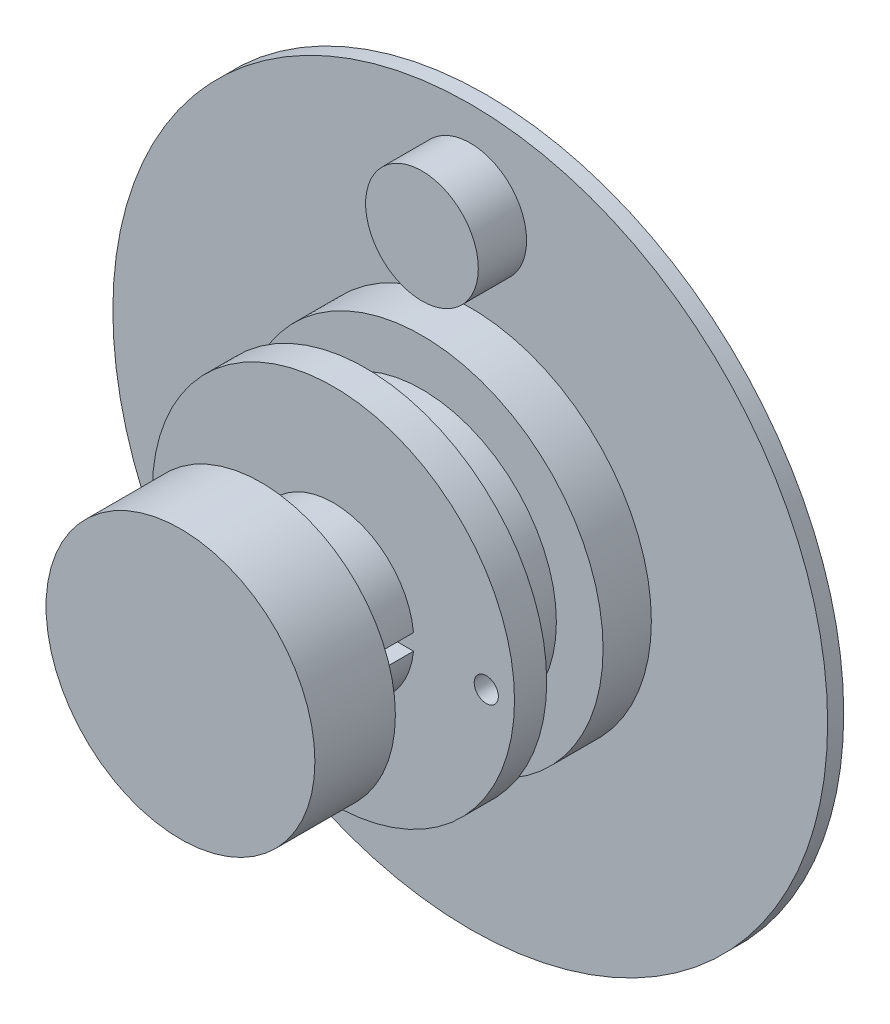
from build123d import *

# Parameters (mm, degrees)
SKETCH1_R           = 22.2
BOSS_EXTRUDE1_DEPTH = 1
BOSS_EXTRUDE2_START = 1
SKETCH2_R           = 11.25
BOSS_EXTRUDE2_DEPTH = 8.5
BOSS_EXTRUDE3_START = 9.5
SKETCH3_R           = 5
BOSS_EXTRUDE3_DEPTH = 9.5
CUT_EXTRUDE1_START  = 19
SKETCH4_W           = 11.621745696
SKETCH4_H           = 1
CUT_EXTRUDE1_DEPTH  = 9.5
BOSS_EXTRUDE4_START = 1
SKETCH5_R           = 3.5
BOSS_EXTRUDE4_DEPTH = 3
SKETCH6_R           = 6
CUT_EXTRUDE2_DEPTH  = 3.5
SKETCH9_R           = 8.35
BOSS_EXTRUDE5_DEPTH = 5
CUT_EXTRUDE7_START  = -2
SKETCH10_R          = 11.25
SKETCH10_R_2        = 8.35
CUT_EXTRUDE7_DEPTH  = 3.5
SKETCH11_R          = 0.75
CUT_EXTRUDE8_DEPTH  = 3


with BuildPart() as part:
    # Sketch1 → Boss-Extrude1 (new body)
    with BuildSketch(Plane.XY):
        Circle(SKETCH1_R)
    extrude(amount=BOSS_EXTRUDE1_DEPTH)

    # Sketch2 → Boss-Extrude2 (add)
    with BuildSketch(Plane.XY.offset(BOSS_EXTRUDE2_START)):
        Circle(SKETCH2_R)
    extrude(amount=BOSS_EXTRUDE2_DEPTH)

    # Sketch3 → Boss-Extrude3 (add)
    with BuildSketch(Plane.XY.offset(BOSS_EXTRUDE3_START)):
        Circle(SKETCH3_R)
    extrude(amount=BOSS_EXTRUDE3_DEPTH)

    # Sketch4 → Cut-Extrude1 (cut)
    with BuildSketch(Plane.XY.offset(CUT_EXTRUDE1_START)):
        Rectangle(SKETCH4_W, SKETCH4_H)
    extrude(amount=-CUT_EXTRUDE1_DEPTH, mode=Mode.SUBTRACT)

    # Sketch5 → Boss-Extrude4 (add)
    with BuildSketch(Plane.XY.offset(BOSS_EXTRUDE4_START)):
        with Locations((0, 16.6)):
            Circle(SKETCH5_R)
    extrude(amount=BOSS_EXTRUDE4_DEPTH)

    # Sketch6 → Cut-Extrude2 (cut)
    with BuildSketch(Plane(origin=(0, 0, 0), x_dir=(-1, 0, 0), z_dir=(0, 0, -1))):
        Circle(SKETCH6_R)
    extrude(amount=-CUT_EXTRUDE2_DEPTH, mode=Mode.SUBTRACT)

    # Sketch9 → Boss-Extrude5 (add)
    with BuildSketch(Plane.XY.offset(19)):
        Circle(SKETCH9_R)
    extrude(amount=-BOSS_EXTRUDE5_DEPTH)

    # Sketch10 → Cut-Extrude7 (cut)
    with BuildSketch(Plane.XY.offset(9.5).offset(CUT_EXTRUDE7_START)):
        Circle(SKETCH10_R)
        Circle(SKETCH10_R_2, mode=Mode.SUBTRACT)
    extrude(amount=-CUT_EXTRUDE7_DEPTH, mode=Mode.SUBTRACT)

    # Sketch11 → Cut-Extrude8 (cut)
    with BuildSketch(Plane.XY.offset(9.5)):
        with Locations((9.495112761, -0.304686158)):
            Circle(SKETCH11_R)
    extrude(amount=-CUT_EXTRUDE8_DEPTH, mode=Mode.SUBTRACT)


solid = part.part
